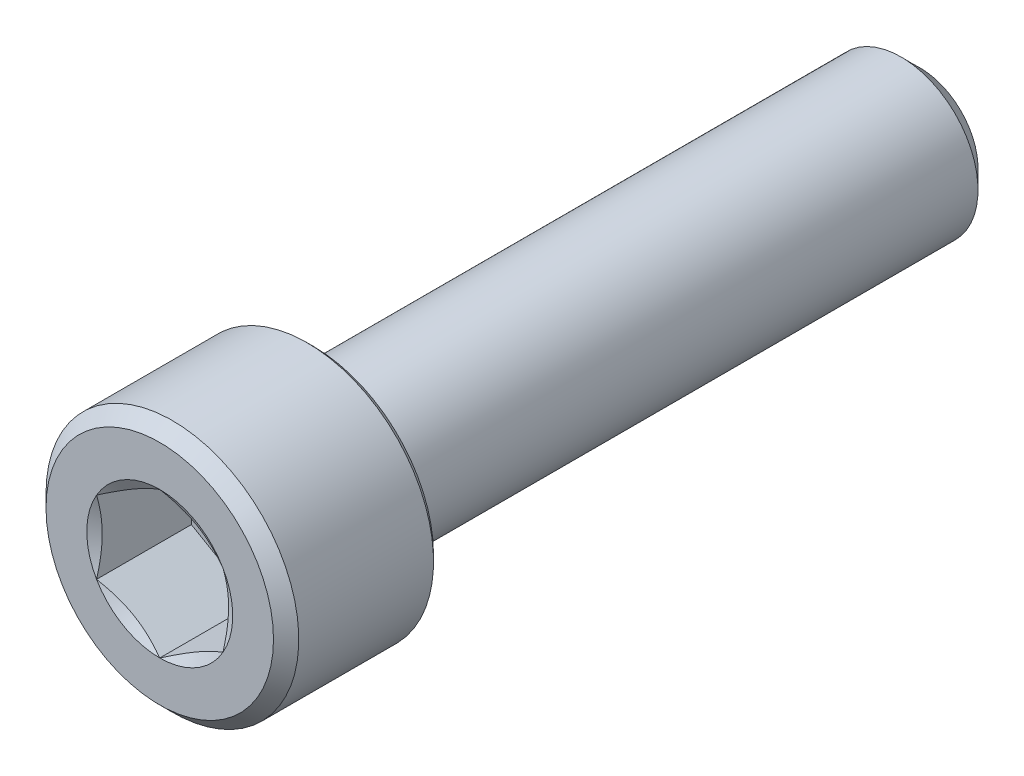
from build123d import *

# Parameters (mm, degrees)
CUT_EXTRUDE1_DEPTH = 2.9765625
CHAMFER1_SIZE      = 0.396875
CHAMFER2_SIZE      = 0.1984375


with BuildPart() as part:
    # Sketch2 → Revolve1 (revolve)
    with BuildSketch(Plane(origin=(0, 0, 0), x_dir=(0, 0, -1), z_dir=(1, 0, 0))):
        Polygon((11.938, 1.8176875), (11.3426875, 2.413), (-7.112, 2.413), (-7.112, 3.96875), (-11.938, 3.96875), (-11.938, 0), (11.938, 0), align=None)
    revolve(axis=Axis((0, 0, -11.938), (0, 0, 1)))

    # Sketch4 → Cut-Extrude1 (cut)
    with BuildSketch(Plane.XY.offset(11.938)):
        Polygon((0, 2.291358881), (-1.984375, 1.14567944), (-1.984375, -1.14567944), (0, -2.291358881), (1.984375, -1.14567944), (1.984375, 1.14567944), align=None)
    extrude(amount=-CUT_EXTRUDE1_DEPTH, mode=Mode.SUBTRACT)

    # Cut-Extrude2 cone 1 section (through the dimple's axis) → Cut-Extrude2 (revolve, cut)
    with BuildSketch(Plane(origin=(0, 0, 11.938), x_dir=(0, -1, 0), z_dir=(1, 0, 0))):
        Polygon((0, 0), (2.291358881, 0), (0, 1.322916667), align=None)
    revolve(axis=Axis((0, 0, 11.938), (0, 0, -1)), mode=Mode.SUBTRACT)

    # Chamfer1
    chamfer1_edges = [part.edges().sort_by_distance(p)[0] for p in [
        (0, -3.96875, 11.938),
    ]]
    chamfer(chamfer1_edges, length=CHAMFER1_SIZE)

    # Chamfer2
    chamfer2_edges = [part.edges().sort_by_distance(p)[0] for p in [
        (0, -3.96875, 7.112),
    ]]
    chamfer(chamfer2_edges, length=CHAMFER2_SIZE)


solid = part.part
